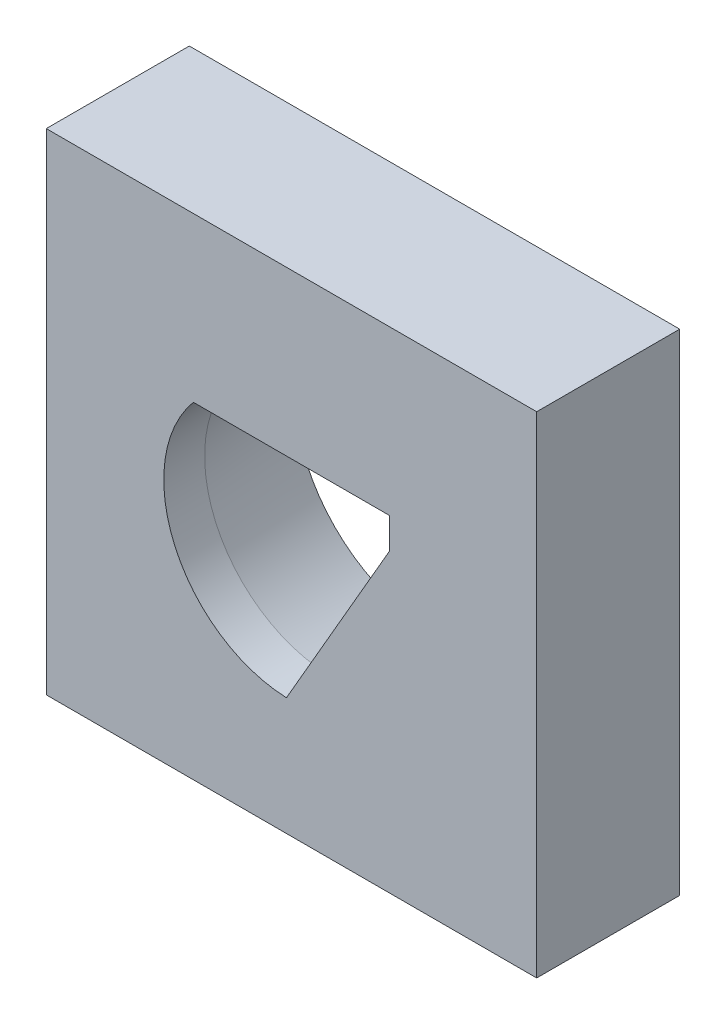
from build123d import *

# Parameters (mm, degrees)
CROQUIS1_W              = 48
CROQUIS1_H              = 48
SALIENTE_EXTRUIR1_DEPTH = 5
CORTAR_EXTRUIR1_DEPTH   = 11
CORTAR_EXTRUIR1_DRAFT   = 7
CROQUIS3_W              = 48
CROQUIS3_H              = 48
SALIENTE_EXTRUIR2_DEPTH = 4


with BuildPart() as part:
    # Croquis1 → Saliente-Extruir1 (new, symmetric)
    with BuildSketch(Plane.XY):
        Rectangle(CROQUIS1_W, CROQUIS1_H)
    extrude(amount=SALIENTE_EXTRUIR1_DEPTH, both=True)


with BuildPart() as cortar_extruir1_tool:
    # Croquis2 → Cortar-Extruir1 (with draft: the straight prism first)
    with BuildSketch(Plane.XY.offset(5)):
        with BuildLine():
            ThreePointArc((-9.604686356, 8), (-11.421696131, -5.078863799), (-0.493320879, -12.490261587))
            Line((-0.493320879, -12.490261587), (9.604686356, 5))
            Line((9.604686356, 5), (9.604686356, 8))
            Line((9.604686356, 8), (-9.604686356, 8))
        make_face()
    extrude(amount=-CORTAR_EXTRUIR1_DEPTH)
    # Cortar-Extruir1: the draft: its side faces are tilted about the plane it starts from
    cortar_extruir1_sides = [cortar_extruir1_tool.faces().sort_by_distance(p)[0] for p in [
        (4.555682738, -3.745130793, -0.5),
        (9.604686356, 6.5, -0.5),
        (0, 8, -0.5),
        (-11.421696131, -5.078863799, -0.5),
    ]]
    draft(cortar_extruir1_sides, Plane.XY.offset(5), CORTAR_EXTRUIR1_DRAFT)


with BuildPart() as part_1:
    add(part.part)

    # Cortar-Extruir1: cut by cortar_extruir1_tool
    add(cortar_extruir1_tool.part, mode=Mode.SUBTRACT)

    # Croquis3 → Saliente-Extruir2 (add)
    with BuildSketch(Plane.XY.offset(5)):
        Rectangle(CROQUIS3_W, CROQUIS3_H)
        with BuildLine():
            Line((9.604686356, 8), (9.604686356, 5))
            Line((9.604686356, 5), (-0.493320879, -12.490261587))
            ThreePointArc((-0.493320879, -12.490261587), (-11.421696131, -5.078863799), (-9.604686356, 8))
            Line((-9.604686356, 8), (9.604686356, 8))
        make_face(mode=Mode.SUBTRACT)
    extrude(amount=SALIENTE_EXTRUIR2_DEPTH)


solid = part_1.part
